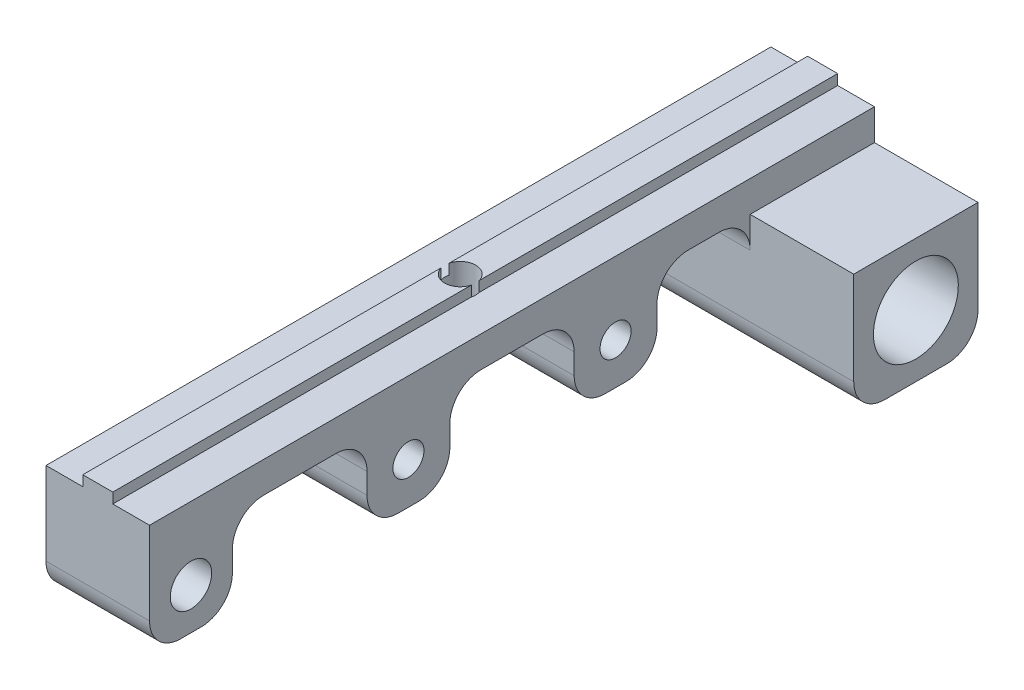
from build123d import *

# Parameters (mm, degrees)
MAKERBEAMFIX_DEPTH                      = 35
SKETCH2_R                               = 1.5
MAKERBEAMFIXHOLE_DEPTH                  = 5
SKETCH3_W                               = 12
SKETCH3_H                               = 12
SKETCH3_R                               = 4.1
MAKERBEAMTOOLBIGHEXASCREWDRIVER_DEPTH   = 20
SKETCH4_W                               = 8
SKETCH4_H                               = 8
SKETCH4_R                               = 1.5
MAKERBEAMTOOLSMALLHEXASCREWDRIVER_DEPTH = 10
SIMPLESCREWDRIVER3MM_COUNT              = 2
SIMPLESCREWDRIVER3MM_PITCH              = 20
SKETCH5_W                               = 8
SKETCH5_H                               = 8
SKETCH5_R                               = 2
BOSS_EXTRUDE4_DEPTH                     = 10
FILLET1_R                               = 3


with BuildPart() as part:
    # Sketch1 → MakerBeamFix (new body, symmetric)
    with BuildSketch(Plane.XY):
        Polygon((-5, 0), (5, 0), (5, 3), (1.45, 3), (1.45, 4), (-1.45, 4), (-1.45, 3), (-5, 3), align=None)
    extrude(amount=MAKERBEAMFIX_DEPTH, both=True)

    # Sketch2 → MakerBeamFixHole (cut, through all)
    with BuildSketch(Plane(origin=(0, 0, 0), x_dir=(-1, 0, 0), z_dir=(0, -1, 0))):
        Circle(SKETCH2_R)
    extrude(amount=-MAKERBEAMFIXHOLE_DEPTH, mode=Mode.SUBTRACT)

    # Sketch3 → MakerBeamToolBigHexaScrewDriver (add)
    with BuildSketch(Plane.ZY.offset(5)):
        with Locations((-29, -6)):
            Rectangle(SKETCH3_W, SKETCH3_H)
        with Locations((-29, -6)):
            Circle(SKETCH3_R, mode=Mode.SUBTRACT)
    extrude(amount=-MAKERBEAMTOOLBIGHEXASCREWDRIVER_DEPTH)

    # Sketch4 → MakerBeamToolSmallHexaScrewDriver (add)
    with BuildSketch(Plane.ZY.offset(5)):
        with Locations((-10, -4)):
            Rectangle(SKETCH4_W, SKETCH4_H)
        with Locations((-10, -4)):
            Circle(SKETCH4_R, mode=Mode.SUBTRACT)
    makerbeamtoolsmallhexascrewdriver = extrude(amount=-MAKERBEAMTOOLSMALLHEXASCREWDRIVER_DEPTH)

    # SimpleScrewDriver3mm: MakerBeamToolSmallHexaScrewDriver ×2
    with Locations(*[(0, 0, i * SIMPLESCREWDRIVER3MM_PITCH) for i in range(1, SIMPLESCREWDRIVER3MM_COUNT)]):
        add(makerbeamtoolsmallhexascrewdriver)

    # Sketch5 → Boss-Extrude4 (add)
    with BuildSketch(Plane.ZY.offset(5)):
        with Locations((31, -4)):
            Rectangle(SKETCH5_W, SKETCH5_H)
        with Locations((31, -4)):
            Circle(SKETCH5_R, mode=Mode.SUBTRACT)
    extrude(amount=-BOSS_EXTRUDE4_DEPTH)

    # Fillet1
    fillet1_edges = [part.edges().sort_by_distance(p)[0] for p in [
        (0, 0, -23),
        (5, -12, -35),
        (5, -12, -23),
        (0, 0, -6),
        (0, -8, -6),
        (0, -8, -14),
        (0, 0, -14),
        (0, 0, 14),
        (0, -8, 14),
        (0, -8, 6),
        (0, 0, 6),
        (0, -8, 35),
        (0, -8, 27),
        (0, 0, 27),
    ]]
    fillet(fillet1_edges, radius=FILLET1_R)


solid = part.part
